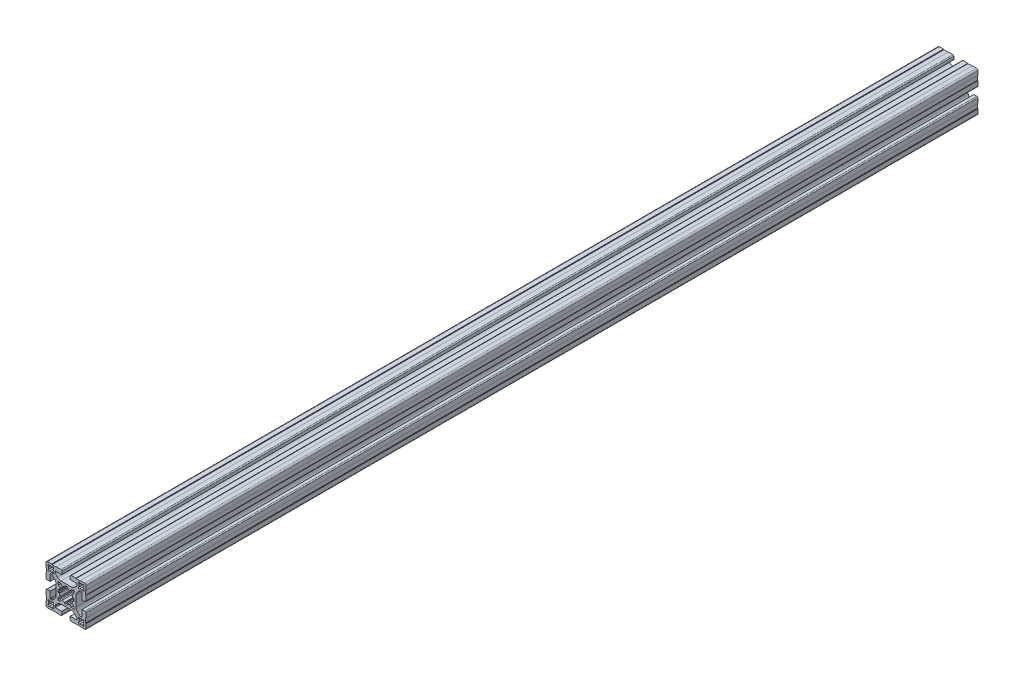
from build123d import *

# Parameters (mm, degrees)
RESSALTO_EXTRUS_O1_DEPTH = 445


with BuildPart() as part:
    # Esboço1 → Ressalto-extrusão1 (new body, symmetric)
    with BuildSketch(Plane.XY):
        with BuildLine():
            Line((4.14998475, -18.79998475), (4.14998475, -15.899980918))
            ThreePointArc((4.14998475, -15.899980918), (4.179274222, -15.829270089), (4.249985176, -15.799980918))
            Line((4.249985176, -15.799980918), (10.499997871, -15.800007531))
            ThreePointArc((10.499997871, -15.800007531), (10.853552638, -15.653561674), (11, -15.300007531))
            Line((11, -15.300007531), (11, -14.449747468))
            ThreePointArc((11, -14.449747468), (10.885819299, -13.87572232), (10.560660172, -13.389087297))
            Line((10.560660172, -13.389087297), (8.636038969, -11.464466094))
            ThreePointArc((8.636038969, -11.464466094), (7.013922225, -10.380602337), (5.100505063, -10))
            Line((5.100505063, -10), (0, -10))
            Line((0, -10), (-5.100505063, -10))
            ThreePointArc((-5.100505063, -10), (-7.013922225, -10.380602337), (-8.636038969, -11.464466094))
            Line((-8.636038969, -11.464466094), (-10.560660172, -13.389087297))
            ThreePointArc((-10.560660172, -13.389087297), (-10.885819299, -13.87572232), (-11, -14.449747468))
            Line((-11, -14.449747468), (-11, -15.300007531))
            ThreePointArc((-11, -15.300007531), (-10.853552638, -15.653561674), (-10.499997871, -15.800007531))
            Line((-10.499997871, -15.800007531), (-4.249985176, -15.799980918))
            ThreePointArc((-4.249985176, -15.799980918), (-4.179274222, -15.829270089), (-4.14998475, -15.899980918))
            Line((-4.14998475, -15.899980918), (-4.14998475, -18.79998475))
            ThreePointArc((-4.14998475, -18.79998475), (-4.442876463, -19.507090026), (-5.149980492, -19.79998475))
            Line((-5.149980492, -19.79998475), (-9.79996495, -19.80000455))
            Line((-9.79996495, -19.80000455), (-9.99998475, -19.59998475))
            Line((-9.99998475, -19.59998475), (-13.99998475, -19.59998475))
            Line((-13.99998475, -19.59998475), (-14.40000475, -20.00000475))
            Line((-14.40000475, -20.00000475), (-18.50000475, -20.00000475))
            ThreePointArc((-18.50000475, -20.00000475), (-19.560664922, -19.560664922), (-20.00000475, -18.50000475))
            Line((-20.00000475, -18.50000475), (-20.00000475, -14.40000475))
            Line((-20.00000475, -14.40000475), (-19.59998475, -13.99998475))
            Line((-19.59998475, -13.99998475), (-19.59998475, -9.99998475))
            Line((-19.59998475, -9.99998475), (-19.800004551, -9.799964949))
            Line((-19.800004551, -9.799964949), (-19.799984751, -5.149980488))
            ThreePointArc((-19.799984751, -5.149980488), (-19.507090026, -4.442876459), (-18.79998475, -4.149984746))
            Line((-18.79998475, -4.149984746), (-15.899980918, -4.149984746))
            ThreePointArc((-15.899980918, -4.149984746), (-15.829270089, -4.179274218), (-15.799980918, -4.249985172))
            Line((-15.799980918, -4.249985172), (-15.800007532, -10.499997871))
            ThreePointArc((-15.800007532, -10.499997871), (-15.653561675, -10.853552638), (-15.300007532, -11))
            Line((-15.300007532, -11), (-14.449747468, -11))
            ThreePointArc((-14.449747468, -11), (-13.87572232, -10.885819298), (-13.389087297, -10.560660171))
            Line((-13.389087297, -10.560660171), (-11.464466094, -8.636038969))
            ThreePointArc((-11.464466094, -8.636038969), (-10.380602337, -7.013922225), (-10, -5.100505063))
            Line((-10, -5.100505063), (-10, 0))
            Line((-10, 0), (-10, 5.100505064))
            ThreePointArc((-10, 5.100505064), (-10.380602337, 7.013922225), (-11.464466094, 8.63603897))
            Line((-11.464466094, 8.63603897), (-13.389087297, 10.560660172))
            ThreePointArc((-13.389087297, 10.560660172), (-13.87572232, 10.885819299), (-14.449747468, 11))
            Line((-14.449747468, 11), (-15.300007532, 11))
            ThreePointArc((-15.300007532, 11), (-15.653561675, 10.853552638), (-15.800007532, 10.499997871))
            Line((-15.800007532, 10.499997871), (-15.799980918, 4.249985172))
            ThreePointArc((-15.799980918, 4.249985172), (-15.829270089, 4.179274219), (-15.899980918, 4.149984747))
            Line((-15.899980918, 4.149984747), (-18.79998475, 4.149984747))
            ThreePointArc((-18.79998475, 4.149984747), (-19.507090026, 4.44287646), (-19.799984751, 5.149980488))
            Line((-19.799984751, 5.149980488), (-19.800004551, 9.79996495))
            Line((-19.800004551, 9.79996495), (-19.59998475, 9.999984751))
            Line((-19.59998475, 9.999984751), (-19.59998475, 13.999984751))
            Line((-19.59998475, 13.999984751), (-20.00000475, 14.400004751))
            Line((-20.00000475, 14.400004751), (-20.00000475, 18.500004751))
            ThreePointArc((-20.00000475, 18.500004751), (-19.560664922, 19.560664922), (-18.50000475, 20.000004751))
            Line((-18.50000475, 20.000004751), (-14.40000475, 20.000004751))
            Line((-14.40000475, 20.000004751), (-13.99998475, 19.599984751))
            Line((-13.99998475, 19.599984751), (-9.99998475, 19.599984751))
            Line((-9.99998475, 19.599984751), (-9.79996495, 19.800004551))
            Line((-9.79996495, 19.800004551), (-5.149980492, 19.799984751))
            ThreePointArc((-5.149980492, 19.799984751), (-4.442876463, 19.507090026), (-4.14998475, 18.799984751))
            Line((-4.14998475, 18.799984751), (-4.14998475, 15.899980918))
            ThreePointArc((-4.14998475, 15.899980918), (-4.179274222, 15.82927009), (-4.249985176, 15.799980918))
            Line((-4.249985176, 15.799980918), (-10.499997871, 15.800007531))
            ThreePointArc((-10.499997871, 15.800007531), (-10.853552638, 15.653561675), (-11, 15.300007531))
            Line((-11, 15.300007531), (-11, 14.449747469))
            ThreePointArc((-11, 14.449747469), (-10.885819299, 13.87572232), (-10.560660172, 13.389087297))
            Line((-10.560660172, 13.389087297), (-8.636038969, 11.464466095))
            ThreePointArc((-8.636038969, 11.464466095), (-7.013922225, 10.380602338), (-5.100505063, 10.000000001))
            Line((-5.100505063, 10.000000001), (0, 10.000000001))
            Line((0, 10.000000001), (5.100505063, 10.000000001))
            ThreePointArc((5.100505063, 10.000000001), (7.013922225, 10.380602338), (8.636038969, 11.464466095))
            Line((8.636038969, 11.464466095), (10.560660172, 13.389087297))
            ThreePointArc((10.560660172, 13.389087297), (10.885819299, 13.87572232), (11, 14.449747469))
            Line((11, 14.449747469), (11, 15.300007531))
            ThreePointArc((11, 15.300007531), (10.853552638, 15.653561675), (10.499997871, 15.800007531))
            Line((10.499997871, 15.800007531), (4.249985176, 15.799980918))
            ThreePointArc((4.249985176, 15.799980918), (4.179274222, 15.82927009), (4.14998475, 15.899980918))
            Line((4.14998475, 15.899980918), (4.14998475, 18.799984751))
            ThreePointArc((4.14998475, 18.799984751), (4.442876463, 19.507090026), (5.149980492, 19.799984751))
            Line((5.149980492, 19.799984751), (9.79996495, 19.800004551))
            Line((9.79996495, 19.800004551), (9.99998475, 19.599984751))
            Line((9.99998475, 19.599984751), (13.99998475, 19.599984751))
            Line((13.99998475, 19.599984751), (14.40000475, 20.000004751))
            Line((14.40000475, 20.000004751), (18.50000475, 20.000004751))
            ThreePointArc((18.50000475, 20.000004751), (19.560664922, 19.560664922), (20.00000475, 18.500004751))
            Line((20.00000475, 18.500004751), (20.00000475, 14.400004751))
            Line((20.00000475, 14.400004751), (19.59998475, 13.999984751))
            Line((19.59998475, 13.999984751), (19.59998475, 9.999984751))
            Line((19.59998475, 9.999984751), (19.800004551, 9.79996495))
            Line((19.800004551, 9.79996495), (19.799984751, 5.149980488))
            ThreePointArc((19.799984751, 5.149980488), (19.507090026, 4.44287646), (18.79998475, 4.149984747))
            Line((18.79998475, 4.149984747), (15.899980918, 4.149984747))
            ThreePointArc((15.899980918, 4.149984747), (15.829270089, 4.179274219), (15.799980918, 4.249985172))
            Line((15.799980918, 4.249985172), (15.800007532, 10.499997871))
            ThreePointArc((15.800007532, 10.499997871), (15.653561675, 10.853552638), (15.300007532, 11))
            Line((15.300007532, 11), (14.449747468, 11))
            ThreePointArc((14.449747468, 11), (13.87572232, 10.885819299), (13.389087297, 10.560660172))
            Line((13.389087297, 10.560660172), (11.464466094, 8.63603897))
            ThreePointArc((11.464466094, 8.63603897), (10.380602337, 7.013922225), (10, 5.100505064))
            Line((10, 5.100505064), (10, 0))
            Line((10, 0), (10, -5.100505063))
            ThreePointArc((10, -5.100505063), (10.380602337, -7.013922225), (11.464466094, -8.636038969))
            Line((11.464466094, -8.636038969), (13.389087297, -10.560660171))
            ThreePointArc((13.389087297, -10.560660171), (13.87572232, -10.885819298), (14.449747468, -11))
            Line((14.449747468, -11), (15.300007532, -11))
            ThreePointArc((15.300007532, -11), (15.653561675, -10.853552638), (15.800007532, -10.499997871))
            Line((15.800007532, -10.499997871), (15.799980918, -4.249985172))
            ThreePointArc((15.799980918, -4.249985172), (15.829270089, -4.179274218), (15.899980918, -4.149984746))
            Line((15.899980918, -4.149984746), (18.79998475, -4.149984746))
            ThreePointArc((18.79998475, -4.149984746), (19.507090026, -4.442876459), (19.799984751, -5.149980488))
            Line((19.799984751, -5.149980488), (19.800004551, -9.799964949))
            Line((19.800004551, -9.799964949), (19.59998475, -9.99998475))
            Line((19.59998475, -9.99998475), (19.59998475, -13.99998475))
            Line((19.59998475, -13.99998475), (20.00000475, -14.40000475))
            Line((20.00000475, -14.40000475), (20.00000475, -18.50000475))
            ThreePointArc((20.00000475, -18.50000475), (19.560664922, -19.560664922), (18.50000475, -20.00000475))
            Line((18.50000475, -20.00000475), (14.40000475, -20.00000475))
            Line((14.40000475, -20.00000475), (13.99998475, -19.59998475))
            Line((13.99998475, -19.59998475), (9.99998475, -19.59998475))
            Line((9.99998475, -19.59998475), (9.79996495, -19.80000455))
            Line((9.79996495, -19.80000455), (5.149980492, -19.79998475))
            ThreePointArc((5.149980492, -19.79998475), (4.442876463, -19.507090026), (4.14998475, -18.79998475))
        make_face()
        with BuildLine():
            Line((-17.857240871, 16.796580699), (-17.416672281, 16.356012109))
            ThreePointArc((-17.416672281, 16.356012109), (-17.7, 15.2), (-17.416672281, 14.04398789))
            Line((-17.416672281, 14.04398789), (-17.857240871, 13.603419301))
            ThreePointArc((-17.857240871, 13.603419301), (-17.857240871, 12.542759129), (-16.796580699, 12.542759129))
            Line((-16.796580699, 12.542759129), (-16.35601211, 12.983327719))
            ThreePointArc((-16.35601211, 12.983327719), (-15.2, 12.7), (-14.04398789, 12.983327719))
            Line((-14.04398789, 12.983327719), (-13.603419301, 12.542759129))
            ThreePointArc((-13.603419301, 12.542759129), (-12.542759129, 12.542759129), (-12.542759129, 13.603419301))
            Line((-12.542759129, 13.603419301), (-12.983327719, 14.04398789))
            ThreePointArc((-12.983327719, 14.04398789), (-12.7, 15.2), (-12.983327719, 16.356012109))
            Line((-12.983327719, 16.356012109), (-12.542759081, 16.796580747))
            ThreePointArc((-12.542759081, 16.796580747), (-12.542759081, 17.857240919), (-13.603419253, 17.857240919))
            Line((-13.603419253, 17.857240919), (-14.04398789, 17.416672281))
            ThreePointArc((-14.04398789, 17.416672281), (-15.2, 17.7), (-16.35601211, 17.416672281))
            Line((-16.35601211, 17.416672281), (-16.796580699, 17.857240871))
            ThreePointArc((-16.796580699, 17.857240871), (-17.857240871, 17.857240871), (-17.857240871, 16.796580699))
        make_face(mode=Mode.SUBTRACT)
        with BuildLine():
            Line((17.416672281, 14.04398789), (17.857240871, 13.603419301))
            ThreePointArc((17.857240871, 13.603419301), (17.857240871, 12.542759129), (16.796580699, 12.542759129))
            Line((16.796580699, 12.542759129), (16.35601211, 12.983327719))
            ThreePointArc((16.35601211, 12.983327719), (15.2, 12.7), (14.043987891, 12.983327719))
            Line((14.043987891, 12.983327719), (13.603419301, 12.542759129))
            ThreePointArc((13.603419301, 12.542759129), (12.542759129, 12.542759129), (12.542759129, 13.603419301))
            Line((12.542759129, 13.603419301), (12.983327719, 14.04398789))
            ThreePointArc((12.983327719, 14.04398789), (12.7, 15.2), (12.983327719, 16.356012109))
            Line((12.983327719, 16.356012109), (12.542759081, 16.796580747))
            ThreePointArc((12.542759081, 16.796580747), (12.542759081, 17.857240919), (13.603419253, 17.857240919))
            Line((13.603419253, 17.857240919), (14.043987891, 17.416672281))
            ThreePointArc((14.043987891, 17.416672281), (15.2, 17.7), (16.35601211, 17.416672281))
            Line((16.35601211, 17.416672281), (16.796580699, 17.857240871))
            ThreePointArc((16.796580699, 17.857240871), (17.857240871, 17.857240871), (17.857240871, 16.796580699))
            Line((17.857240871, 16.796580699), (17.416672281, 16.356012109))
            ThreePointArc((17.416672281, 16.356012109), (17.7, 15.2), (17.416672281, 14.04398789))
        make_face(mode=Mode.SUBTRACT)
        with BuildLine():
            Line((-17.416672281, -14.04398789), (-17.857240871, -13.603419301))
            ThreePointArc((-17.857240871, -13.603419301), (-17.857240871, -12.542759129), (-16.796580699, -12.542759129))
            Line((-16.796580699, -12.542759129), (-16.35601211, -12.983327719))
            ThreePointArc((-16.35601211, -12.983327719), (-15.2, -12.7), (-14.04398789, -12.983327719))
            Line((-14.04398789, -12.983327719), (-13.603419301, -12.542759129))
            ThreePointArc((-13.603419301, -12.542759129), (-12.542759129, -12.542759129), (-12.542759129, -13.603419301))
            Line((-12.542759129, -13.603419301), (-12.983327719, -14.04398789))
            ThreePointArc((-12.983327719, -14.04398789), (-12.7, -15.2), (-12.983327719, -16.35601211))
            Line((-12.983327719, -16.35601211), (-12.542759081, -16.796580747))
            ThreePointArc((-12.542759081, -16.796580747), (-12.542759081, -17.857240919), (-13.603419253, -17.857240919))
            Line((-13.603419253, -17.857240919), (-14.04398789, -17.416672281))
            ThreePointArc((-14.04398789, -17.416672281), (-15.2, -17.7), (-16.35601211, -17.416672281))
            Line((-16.35601211, -17.416672281), (-16.796580699, -17.857240871))
            ThreePointArc((-16.796580699, -17.857240871), (-17.857240871, -17.857240871), (-17.857240871, -16.796580699))
            Line((-17.857240871, -16.796580699), (-17.416672281, -16.35601211))
            ThreePointArc((-17.416672281, -16.35601211), (-17.7, -15.2), (-17.416672281, -14.04398789))
        make_face(mode=Mode.SUBTRACT)
        with BuildLine():
            Line((17.857240871, -16.796580699), (17.416672281, -16.35601211))
            ThreePointArc((17.416672281, -16.35601211), (17.7, -15.2), (17.416672281, -14.04398789))
            Line((17.416672281, -14.04398789), (17.857240871, -13.603419301))
            ThreePointArc((17.857240871, -13.603419301), (17.857240871, -12.542759129), (16.796580699, -12.542759129))
            Line((16.796580699, -12.542759129), (16.35601211, -12.983327719))
            ThreePointArc((16.35601211, -12.983327719), (15.2, -12.7), (14.043987891, -12.983327719))
            Line((14.043987891, -12.983327719), (13.603419301, -12.542759129))
            ThreePointArc((13.603419301, -12.542759129), (12.542759129, -12.542759129), (12.542759129, -13.603419301))
            Line((12.542759129, -13.603419301), (12.983327719, -14.04398789))
            ThreePointArc((12.983327719, -14.04398789), (12.7, -15.2), (12.983327719, -16.35601211))
            Line((12.983327719, -16.35601211), (12.542759081, -16.796580747))
            ThreePointArc((12.542759081, -16.796580747), (12.542759081, -17.857240919), (13.603419253, -17.857240919))
            Line((13.603419253, -17.857240919), (14.043987891, -17.416672281))
            ThreePointArc((14.043987891, -17.416672281), (15.2, -17.7), (16.35601211, -17.416672281))
            Line((16.35601211, -17.416672281), (16.796580699, -17.857240871))
            ThreePointArc((16.796580699, -17.857240871), (17.857240871, -17.857240871), (17.857240871, -16.796580699))
        make_face(mode=Mode.SUBTRACT)
        with BuildLine():
            Line((-5.31389005, -7.63550963), (-7.648765071, -8.261137506))
            ThreePointArc((-7.648765071, -8.261137506), (-8.131727984, -8.131727984), (-8.261137506, -7.64876507))
            Line((-8.261137506, -7.64876507), (-7.63550963, -5.313890049))
            ThreePointArc((-7.63550963, -5.313890049), (-7.568281523, -5.165514456), (-7.456927431, -5.046622902))
            Line((-7.456927431, -5.046622902), (-5.743958929, -3.73221594))
            ThreePointArc((-5.743958929, -3.73221594), (-6.328574798, -2.621381512), (-6.70066751, -1.422517109))
            Line((-6.70066751, -1.422517109), (-7.520425705, -1.314593895))
            ThreePointArc((-7.520425705, -1.314593895), (-7.812495975, -1.168604027), (-7.952173449, -0.873462896))
            ThreePointArc((-7.952173449, -0.873462896), (-8, 0), (-7.952173449, 0.873462896))
            ThreePointArc((-7.952173449, 0.873462896), (-7.812495975, 1.168604027), (-7.520425705, 1.314593895))
            Line((-7.520425705, 1.314593895), (-6.70066751, 1.422517109))
            ThreePointArc((-6.70066751, 1.422517109), (-6.328574798, 2.621381512), (-5.743958929, 3.73221594))
            Line((-5.743958929, 3.73221594), (-7.456927431, 5.046622902))
            ThreePointArc((-7.456927431, 5.046622902), (-7.568281523, 5.165514456), (-7.63550963, 5.313890049))
            Line((-7.63550963, 5.313890049), (-8.261137506, 7.64876507))
            ThreePointArc((-8.261137506, 7.64876507), (-8.131727984, 8.131727984), (-7.648765071, 8.261137506))
            Line((-7.648765071, 8.261137506), (-5.31389005, 7.63550963))
            ThreePointArc((-5.31389005, 7.63550963), (-5.165514456, 7.568281523), (-5.046622902, 7.456927431))
            Line((-5.046622902, 7.456927431), (-3.73221594, 5.743958929))
            ThreePointArc((-3.73221594, 5.743958929), (-2.621381512, 6.328574798), (-1.422517109, 6.70066751))
            Line((-1.422517109, 6.70066751), (-1.314593895, 7.520425705))
            ThreePointArc((-1.314593895, 7.520425705), (-1.168604027, 7.812495975), (-0.873462896, 7.952173449))
            ThreePointArc((-0.873462896, 7.952173449), (0, 8), (0.873462896, 7.952173449))
            ThreePointArc((0.873462896, 7.952173449), (1.168604027, 7.812495975), (1.314593895, 7.520425705))
            Line((1.314593895, 7.520425705), (1.422517109, 6.70066751))
            ThreePointArc((1.422517109, 6.70066751), (2.621381512, 6.328574798), (3.73221594, 5.743958929))
            Line((3.73221594, 5.743958929), (5.046622902, 7.456927431))
            ThreePointArc((5.046622902, 7.456927431), (5.165514456, 7.568281523), (5.31389005, 7.63550963))
            Line((5.31389005, 7.63550963), (7.648765071, 8.261137506))
            ThreePointArc((7.648765071, 8.261137506), (8.131727984, 8.131727984), (8.261137506, 7.64876507))
            Line((8.261137506, 7.64876507), (7.63550963, 5.313890049))
            ThreePointArc((7.63550963, 5.313890049), (7.568281523, 5.165514456), (7.456927431, 5.046622902))
            Line((7.456927431, 5.046622902), (5.743958929, 3.73221594))
            ThreePointArc((5.743958929, 3.73221594), (6.328574798, 2.621381512), (6.70066751, 1.422517109))
            Line((6.70066751, 1.422517109), (7.520425705, 1.314593895))
            ThreePointArc((7.520425705, 1.314593895), (7.812495975, 1.168604027), (7.952173449, 0.873462896))
            ThreePointArc((7.952173449, 0.873462896), (8, 0), (7.952173449, -0.873462896))
            ThreePointArc((7.952173449, -0.873462896), (7.812495975, -1.168604027), (7.520425705, -1.314593895))
            Line((7.520425705, -1.314593895), (6.70066751, -1.422517109))
            ThreePointArc((6.70066751, -1.422517109), (6.328574798, -2.621381512), (5.743958929, -3.73221594))
            Line((5.743958929, -3.73221594), (7.456927431, -5.046622902))
            ThreePointArc((7.456927431, -5.046622902), (7.568281523, -5.165514456), (7.63550963, -5.313890049))
            Line((7.63550963, -5.313890049), (8.261137506, -7.64876507))
            ThreePointArc((8.261137506, -7.64876507), (8.131727984, -8.131727984), (7.648765071, -8.261137506))
            Line((7.648765071, -8.261137506), (5.31389005, -7.63550963))
            ThreePointArc((5.31389005, -7.63550963), (5.165514456, -7.568281523), (5.046622902, -7.456927431))
            Line((5.046622902, -7.456927431), (3.73221594, -5.743958929))
            ThreePointArc((3.73221594, -5.743958929), (2.621381512, -6.328574798), (1.422517109, -6.70066751))
            Line((1.422517109, -6.70066751), (1.314593895, -7.520425705))
            ThreePointArc((1.314593895, -7.520425705), (1.168604027, -7.812495975), (0.873462896, -7.952173449))
            ThreePointArc((0.873462896, -7.952173449), (0, -8), (-0.873462896, -7.952173449))
            ThreePointArc((-0.873462896, -7.952173449), (-1.168604027, -7.812495975), (-1.314593895, -7.520425705))
            Line((-1.314593895, -7.520425705), (-1.422517109, -6.70066751))
            ThreePointArc((-1.422517109, -6.70066751), (-2.621381512, -6.328574798), (-3.73221594, -5.743958929))
            Line((-3.73221594, -5.743958929), (-5.046622902, -7.456927431))
            ThreePointArc((-5.046622902, -7.456927431), (-5.165514456, -7.568281523), (-5.31389005, -7.63550963))
        make_face(mode=Mode.SUBTRACT)
    extrude(amount=RESSALTO_EXTRUS_O1_DEPTH, both=True)


solid = part.part
